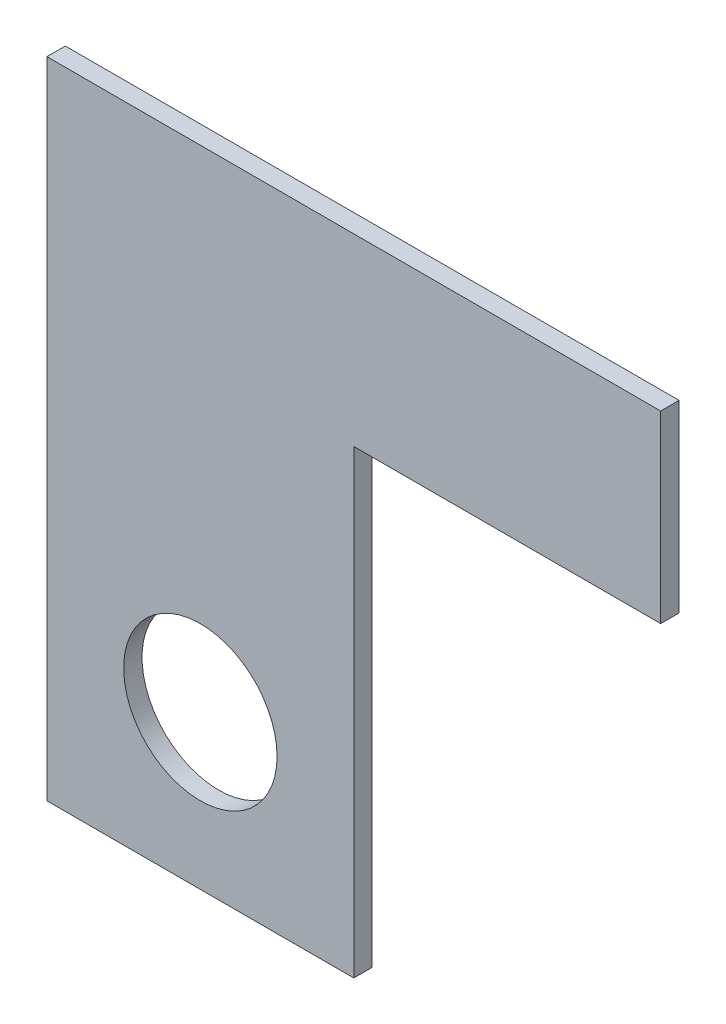
from build123d import *

# Parameters (mm, degrees)
SKETCH1_W           = 50
SKETCH1_H           = 75
SKETCH1_R           = 12.5
BOSS_EXTRUDE1_DEPTH = 3


with BuildPart() as part:
    # Sketch1 → Boss-Extrude1 (new body)
    with BuildSketch(Plane.XY):
        Polygon((-50, 15), (-50, -15), (0, -15), (50, -15), (50, 15), align=None)
        with Locations((-25, -52.5)):
            Rectangle(SKETCH1_W, SKETCH1_H)
        with Locations((-25, -65)):
            Circle(SKETCH1_R, mode=Mode.SUBTRACT)
    extrude(amount=BOSS_EXTRUDE1_DEPTH)


solid = part.part
